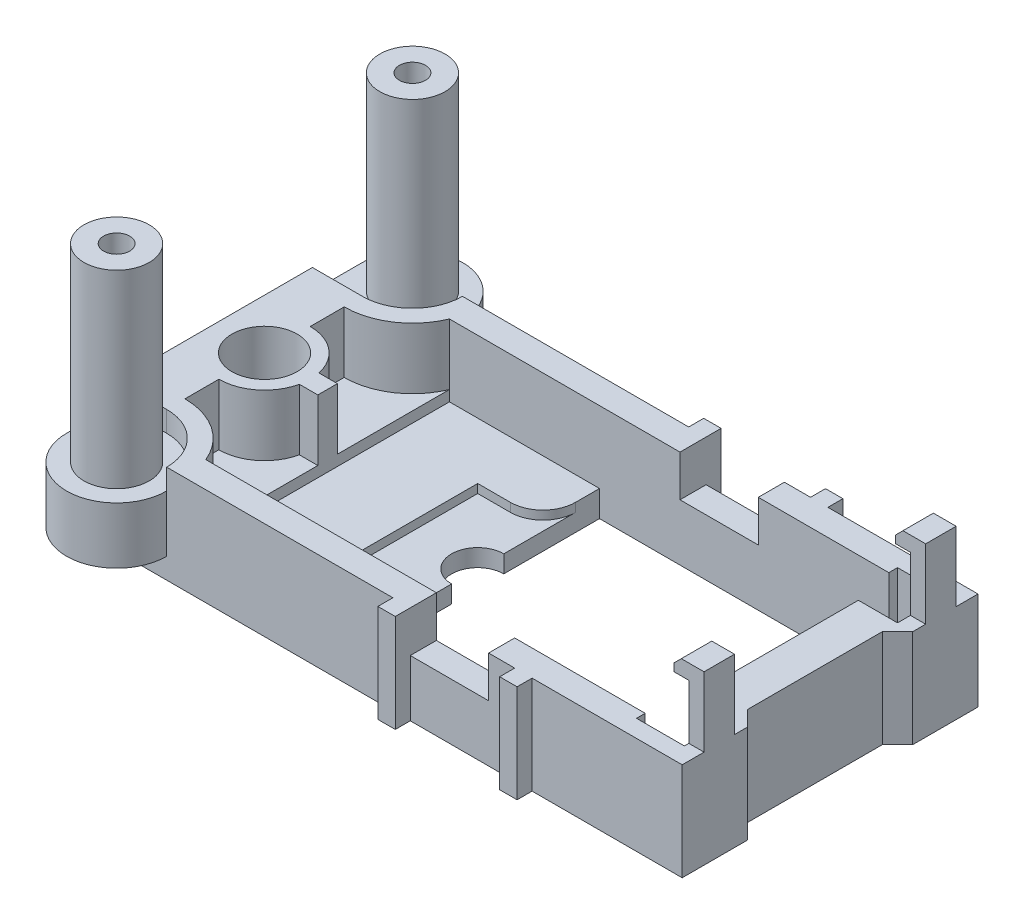
from build123d import *

# Parameters (mm, degrees)
SKETCH1_W           = 35.941
SKETCH1_H           = 17.272
BOSS_EXTRUDE1_DEPTH = 5.715
SKETCH2_W           = 4.572
SKETCH2_H           = 2.413
CUT_EXTRUDE1_DEPTH  = 26.571900188
CUT_EXTRUDE2_DEPTH  = 21.740795338
SKETCH4_W           = 8.763
SKETCH4_H           = 14.224
CUT_EXTRUDE3_DEPTH  = 2.54
SKETCH4_2_W         = 8.763
SKETCH4_2_H         = 14.224
CUT_EXTRUDE4_DEPTH  = 4.191
SKETCH6_W           = 9.652
SKETCH6_H           = 0.8763
BOSS_EXTRUDE2_DEPTH = 0.8763
SKETCH7_W           = 0.889
SKETCH7_H           = 1.778
BOSS_EXTRUDE3_DEPTH = 4.064
SKETCH9_W           = 1.778
SKETCH9_H           = 0.8763
BOSS_EXTRUDE5_DEPTH = 0.8763
CHAMFER1_SIZE       = 0.43815
SKETCH11_W          = 1.016
SKETCH11_H          = 5.715
BOSS_EXTRUDE6_DEPTH = 0.8763
CUT_EXTRUDE5_DEPTH  = 0.508
CUT_EXTRUDE6_DEPTH  = 23.140751806
SKETCH20_W          = 5.842
SKETCH20_H          = 3.302
BOSS_EXTRUDE8_DEPTH = 4.318
CUT_EXTRUDE12_DEPTH = 1.2065
CUT_EXTRUDE13_DEPTH = 23.771103542
SKETCH26_R          = 1.905
SKETCH26_R_2        = 0.762
BOSS_EXTRUDE9_DEPTH = 11.049
SKETCH27_R          = 1.905
CUT_EXTRUDE14_DEPTH = 3.5687
SKETCH29_R          = 0.762
CUT_EXTRUDE15_DEPTH = 26.226244364


with BuildPart() as part:
    # Sketch1 → Boss-Extrude1 (new body)
    with BuildSketch(Plane(origin=(0, 0, 0), x_dir=(1, 0, 0), z_dir=(0, 1, 0))):
        Rectangle(SKETCH1_W, SKETCH1_H)
    extrude(amount=BOSS_EXTRUDE1_DEPTH)

    # Sketch2 → Cut-Extrude1 (cut, through all)
    with BuildSketch(Plane.XY.offset(8.636)):
        with Locations((4.3815, 4.5085)):
            Rectangle(SKETCH2_W, SKETCH2_H)
    extrude(amount=-CUT_EXTRUDE1_DEPTH, mode=Mode.SUBTRACT)

    # Sketch3 → Cut-Extrude2 (cut, through all)
    with BuildSketch(Plane(origin=(0, 5.715, 0), x_dir=(1, 0, 0), z_dir=(0, 1, 0))):
        Polygon((17.0815, 3.937), (17.0815, -3.937), (17.9705, -4.826), (17.9705, 4.826), align=None)
        Polygon((17.0815, 4.826), (17.0815, 7.62), (14.2875, 7.62), (14.2875, 7.112), (-2.6035, 7.112), (-2.6035, -7.112), (14.2875, -7.112), (14.2875, -7.62), (17.0815, -7.62), (17.0815, -4.826), (14.7955, -4.826), (14.7955, 4.826), align=None)
    extrude(amount=-CUT_EXTRUDE2_DEPTH, mode=Mode.SUBTRACT)

    # Sketch4 → Cut-Extrude3 (cut)
    with BuildSketch(Plane(origin=(0, 5.715, 0), x_dir=(1, 0, 0), z_dir=(0, 1, 0))):
        with Locations((-6.985, 0)):
            Rectangle(SKETCH4_W, SKETCH4_H)
    extrude(amount=-CUT_EXTRUDE3_DEPTH, mode=Mode.SUBTRACT)

    # Sketch4_2 → Cut-Extrude4 (cut)
    with BuildSketch(Plane(origin=(0, 5.715, 0), x_dir=(1, 0, 0), z_dir=(0, 1, 0))):
        with Locations((-6.985, 0)):
            Rectangle(SKETCH4_2_W, SKETCH4_2_H)
    extrude(amount=-CUT_EXTRUDE4_DEPTH, mode=Mode.SUBTRACT)

    # Sketch6 → Boss-Extrude2 (add)
    with BuildSketch(Plane.ZY.offset(-14.7955)):
        with Locations((0, 0.43815)):
            Rectangle(SKETCH6_W, SKETCH6_H)
    extrude(amount=BOSS_EXTRUDE2_DEPTH)

    # Sketch7 → Boss-Extrude3 (add)
    with BuildSketch(Plane(origin=(0, 5.715, 0), x_dir=(1, 0, 0), z_dir=(0, 1, 0))):
        with Locations((17.526, 6.470028065)):
            Rectangle(SKETCH7_W, SKETCH7_H)
        with Locations((17.526, -6.470028065)):
            Rectangle(SKETCH7_W, SKETCH7_H)
    extrude(amount=BOSS_EXTRUDE3_DEPTH)

    # Sketch9 → Boss-Extrude5 (add)
    with BuildSketch(Plane.ZY.offset(-17.0815)):
        with Locations((-6.470028065, 9.34085)):
            Rectangle(SKETCH9_W, SKETCH9_H)
        with Locations((6.470028065, 9.34085)):
            Rectangle(SKETCH9_W, SKETCH9_H)
    extrude(amount=BOSS_EXTRUDE5_DEPTH)

    # Chamfer1
    chamfer1_edges = [part.edges().sort_by_distance(p)[0] for p in [
        (16.2052, 9.779, 6.470028065),
        (16.2052, 9.779, -6.470028065),
    ]]
    chamfer(chamfer1_edges, length=CHAMFER1_SIZE)

    # Sketch11 → Boss-Extrude6 (add)
    with BuildSketch(Plane(origin=(0, 0, -8.636), x_dir=(-1, 0, 0), z_dir=(0, 0, -1))):
        with Locations((-1.5875, 2.8575)):
            Rectangle(SKETCH11_W, SKETCH11_H)
        with Locations((-8.6995, 2.8575)):
            Rectangle(SKETCH11_W, SKETCH11_H)
    boss_extrude6 = extrude(amount=BOSS_EXTRUDE6_DEPTH)

    # Mirror1: Boss-Extrude6 across plane
    add(boss_extrude6.mirror(Plane.XY))

    # Sketch12 → Cut-Extrude5 (cut)
    with BuildSketch(Plane(origin=(0, 1.524, 0), x_dir=(1, 0, 0), z_dir=(0, 1, 0))):
        with BuildLine():
            Line((-2.6035, -5.715), (-2.6035, 5.715))
            ThreePointArc((-2.6035, 5.715), (-3.161461582, 4.367961582), (-4.5085, 3.81))
            Line((-4.5085, 3.81), (-6.4135, 3.81))
            Line((-6.4135, 3.81), (-6.4135, -3.81))
            Line((-6.4135, -3.81), (-4.5085, -3.81))
            ThreePointArc((-4.5085, -3.81), (-3.161461582, -4.367961582), (-2.6035, -5.715))
        make_face()
    extrude(amount=-CUT_EXTRUDE5_DEPTH, mode=Mode.SUBTRACT)

    # Sketch13 → Cut-Extrude6 (cut, through all)
    with BuildSketch(Plane(origin=(0, 1.016, 0), x_dir=(1, 0, 0), z_dir=(0, 1, 0))):
        with BuildLine():
            Line((-2.6035, -1.524), (-2.6035, 1.524))
            ThreePointArc((-2.6035, 1.524), (-4.1275, 0), (-2.6035, -1.524))
        make_face()
    extrude(amount=-CUT_EXTRUDE6_DEPTH, mode=Mode.SUBTRACT)

    # Sketch20 → Boss-Extrude8 (add)
    with BuildSketch(Plane.XY.offset(8.636)):
        with Locations((-15.0495, 2.8575)):
            Rectangle(SKETCH20_W, SKETCH20_H)
    boss_extrude8 = extrude(amount=BOSS_EXTRUDE8_DEPTH)

    # Mirror5: Boss-Extrude8 across plane
    add(boss_extrude8.mirror(Plane.XY))

    # Sketch23 → Cut-Extrude12 (cut)
    with BuildSketch(Plane(origin=(0, 5.715, 0), x_dir=(1, 0, 0), z_dir=(0, 1, 0))):
        with BuildLine():
            Line((-15.0495, -5.715), (-17.9705, -5.715))
            Line((-17.9705, -5.715), (-17.9705, -8.636))
            Line((-17.9705, -8.636), (-12.1285, -8.636))
            ThreePointArc((-12.1285, -8.636), (-12.984041092, -6.570541092), (-15.0495, -5.715))
        make_face()
    cut_extrude12 = extrude(amount=-CUT_EXTRUDE12_DEPTH, mode=Mode.SUBTRACT)

    # Mirror8: Cut-Extrude12 across plane
    add(cut_extrude12.mirror(Plane.XY), mode=Mode.SUBTRACT)

    # Sketch25 → Cut-Extrude13 (cut, through all)
    with BuildSketch(Plane(origin=(0, 4.5085, 0), x_dir=(1, 0, 0), z_dir=(0, 1, 0))):
        with BuildLine():
            Line((-12.1285, -8.636), (-12.1285, -12.954))
            Line((-12.1285, -12.954), (-17.9705, -12.954))
            Line((-17.9705, -12.954), (-17.9705, -8.636))
            ThreePointArc((-17.9705, -8.636), (-15.0495, -11.557), (-12.1285, -8.636))
        make_face()
    cut_extrude13 = extrude(amount=-CUT_EXTRUDE13_DEPTH, mode=Mode.SUBTRACT)

    # Mirror9: Cut-Extrude13 across plane
    add(cut_extrude13.mirror(Plane.XY), mode=Mode.SUBTRACT)

    # Sketch26 → Boss-Extrude9 (add)
    with BuildSketch(Plane(origin=(0, 4.5085, 0), x_dir=(1, 0, 0), z_dir=(0, 1, 0))):
        with Locations((-15.0495, -8.636)):
            Circle(SKETCH26_R)
        with Locations((-15.0495, -8.636)):
            Circle(SKETCH26_R_2, mode=Mode.SUBTRACT)
    boss_extrude9 = extrude(amount=BOSS_EXTRUDE9_DEPTH)

    # Mirror10: Boss-Extrude9 across plane
    add(boss_extrude9.mirror(Plane.XY))

    # Sketch27 → Cut-Extrude14 (cut)
    with BuildSketch(Plane(origin=(0, 5.715, 0), x_dir=(1, 0, 0), z_dir=(0, 1, 0))):
        with BuildLine():
            Line((-11.3665, -7.112), (-11.3665, -0.5715))
            Line((-11.3665, -0.5715), (-12.44445168, -0.5715))
            ThreePointArc((-12.44445168, -0.5715), (-13.377869284, -2.078109658), (-15.0495, -2.667))
            Line((-15.0495, -2.667), (-15.0495, -4.650141874))
            ThreePointArc((-15.0495, -4.650141874), (-12.834481127, -5.322277563), (-11.3665, -7.112))
        make_face()
        with BuildLine():
            Line((-12.44445168, 0.5715), (-11.3665, 0.5715))
            Line((-11.3665, 0.5715), (-11.3665, 7.112))
            ThreePointArc((-11.3665, 7.112), (-12.834481127, 5.322277563), (-15.0495, 4.650141874))
            Line((-15.0495, 4.650141874), (-15.0495, 2.667))
            ThreePointArc((-15.0495, 2.667), (-13.377869284, 2.078109658), (-12.44445168, 0.5715))
        make_face()
        with Locations((-15.0495, 0)):
            Circle(SKETCH27_R)
    extrude(amount=-CUT_EXTRUDE14_DEPTH, mode=Mode.SUBTRACT)

    # Sketch29 → Cut-Extrude15 (cut, through all)
    with BuildSketch(Plane(origin=(0, 2.1463, 0), x_dir=(1, 0, 0), z_dir=(0, 1, 0))):
        with Locations((-15.0495, 0)):
            Circle(SKETCH29_R)
    extrude(amount=-CUT_EXTRUDE15_DEPTH, mode=Mode.SUBTRACT)


solid = part.part
